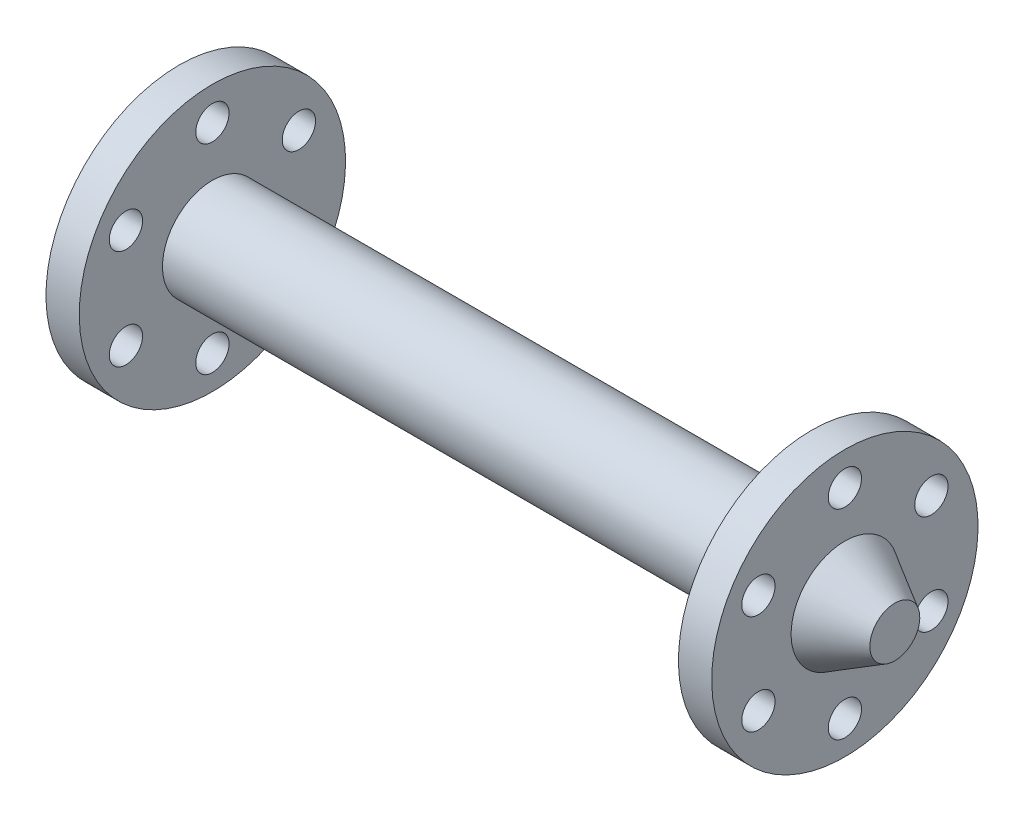
from build123d import *

# Parameters (mm, degrees)
F_1_0MM_DOWEL_HOLE1_D = 20
CIRPATTERN1_COUNT     = 6


with BuildPart() as part:
    # Sketch1 → Revolve1 (revolve)
    with BuildSketch(Plane.XY):
        Polygon((-230, 0), (-230, 15), (-200, 32.320508076), (-200, 80), (-180, 80), (-180, 30), (180, 30), (180, 80), (200, 80), (200, 32.320508076), (230, 15), (230, 0), align=None)
    revolve(axis=Axis((230, 0, 0), (-1, 0, 0)))

    # Ø1.0mm Dowel Hole1 (through all)
    with Locations(Plane.ZY.offset(200)):
        with Locations((0, 60)):
            f_1_0mm_dowel_hole1 = Hole(F_1_0MM_DOWEL_HOLE1_D / 2)

    # CirPattern1: Ø1.0mm Dowel Hole1 ×6 about axis
    cirpattern1_axis = Axis((0, 0, 0), (1, 0, 0))
    for i in range(1, CIRPATTERN1_COUNT):
        add(f_1_0mm_dowel_hole1.rotate(cirpattern1_axis, i * 360 / CIRPATTERN1_COUNT), mode=Mode.SUBTRACT)


solid = part.part
